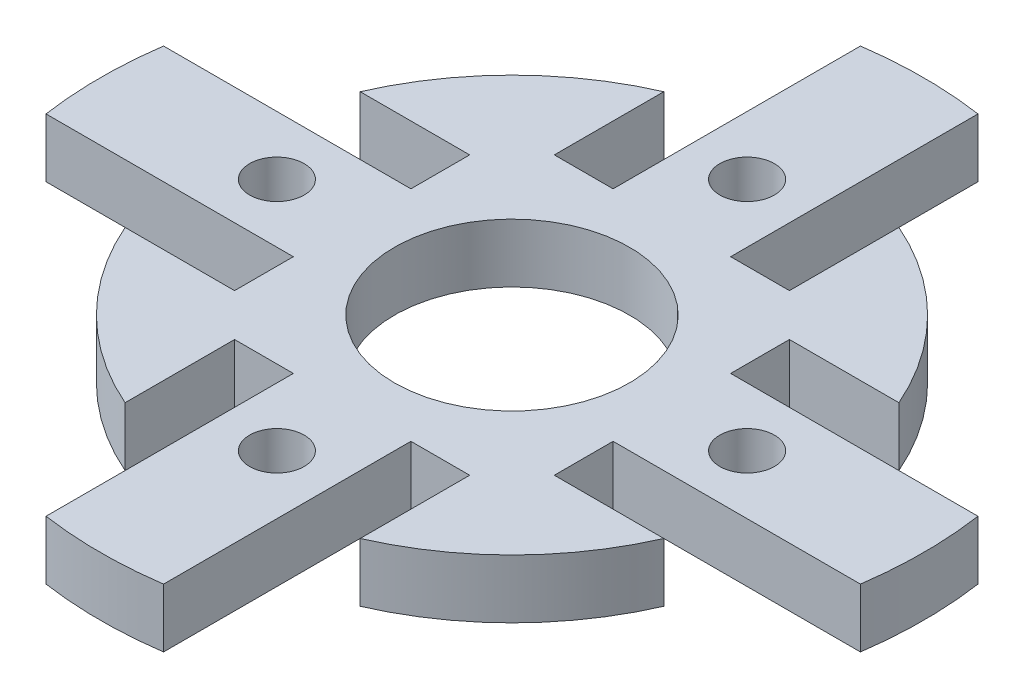
from build123d import *

# Parameters (mm, degrees)
SKETCH1_R                   = 6.35
BOSS_EXTRUDE1_DEPTH         = 3.175
F_4_CLEARANCE_HOLE1_D       = 2.9464
CUT_EXTRUDE1_REACH          = 33.591
SKETCH11_W                  = 3.175
SKETCH11_H                  = 6.918259867
CIRPATTERN2_COUNT           = 4
CIRPATTERN2_COPY_1_REACH    = 33.591
CIRPATTERN2_COPY_1_SKETCH_W = 3.175
CIRPATTERN2_COPY_1_SKETCH_H = 6.918259867
CIRPATTERN2_COPY_2_REACH    = 33.591
CIRPATTERN2_COPY_2_SKETCH_W = 3.175
CIRPATTERN2_COPY_2_SKETCH_H = 6.918259867
CIRPATTERN2_COPY_3_REACH    = 33.591
CIRPATTERN2_COPY_3_SKETCH_W = 3.175
CIRPATTERN2_COPY_3_SKETCH_H = 6.918259867
CIRPATTERN2_COPY_4_REACH    = 33.591
CIRPATTERN2_COPY_4_SKETCH_W = 3.175
CIRPATTERN2_COPY_4_SKETCH_H = 6.918259867
CIRPATTERN2_COPY_5_REACH    = 33.591
CIRPATTERN2_COPY_5_SKETCH_W = 3.175
CIRPATTERN2_COPY_5_SKETCH_H = 6.918259867
CIRPATTERN2_COPY_6_REACH    = 33.591
CIRPATTERN2_COPY_6_SKETCH_W = 3.175
CIRPATTERN2_COPY_6_SKETCH_H = 6.918259867


with BuildPart() as part:
    # Sketch1 → Boss-Extrude1 (new body)
    with BuildSketch(Plane(origin=(0, 0, 0), x_dir=(1, 0, 0), z_dir=(0, 1, 0))):
        with BuildLine():
            Line((-3.175, 21.997045256), (-3.175, 15.554259867))
            ThreePointArc((-3.175, 15.554259867), (-11.225320151, 11.225320151), (-15.554259867, 3.175))
            Line((-15.554259867, 3.175), (-21.997045256, 3.175))
            ThreePointArc((-21.997045256, 3.175), (-22.225, 0), (-21.997045256, -3.175))
            Line((-21.997045256, -3.175), (-15.554259867, -3.175))
            ThreePointArc((-15.554259867, -3.175), (-11.225320151, -11.225320151), (-3.175, -15.554259867))
            Line((-3.175, -15.554259867), (-3.175, -21.997045256))
            ThreePointArc((-3.175, -21.997045256), (0, -22.225), (3.175, -21.997045256))
            Line((3.175, -21.997045256), (3.175, -15.554259867))
            ThreePointArc((3.175, -15.554259867), (11.225320151, -11.225320151), (15.554259867, -3.175))
            Line((15.554259867, -3.175), (21.997045256, -3.175))
            ThreePointArc((21.997045256, -3.175), (22.225, 0), (21.997045256, 3.175))
            Line((21.997045256, 3.175), (15.554259867, 3.175))
            ThreePointArc((15.554259867, 3.175), (11.225320151, 11.225320151), (3.175, 15.554259867))
            Line((3.175, 15.554259867), (3.175, 21.997045256))
            ThreePointArc((3.175, 21.997045256), (0, 22.225), (-3.175, 21.997045256))
        make_face()
        with Locations(Location((0, 0, 0), (0, 0, 270))):
            Circle(SKETCH1_R, mode=Mode.SUBTRACT)
    extrude(amount=BOSS_EXTRUDE1_DEPTH)

    # #4 Clearance Hole1 (through all)
    with Locations(Plane(origin=(-5.152902703, 3.175, -13.741681739), x_dir=(1, 0, 0), z_dir=(0, 1, 0))):
        with Locations((5.152902703, -1.041681739)):
            f_4_clearance_hole1 = Hole(F_4_CLEARANCE_HOLE1_D / 2)

    # Sketch11 → Cut-Extrude1 (cut, up to next)
    with BuildSketch(Plane(origin=(0, 3.175, 0), x_dir=(1, 0, 0), z_dir=(0, 1, 0)), mode=Mode.PRIVATE) as cut_extrude1_sk1:
        with Locations((-4.7625, 12.095129934)):
            Rectangle(SKETCH11_W, SKETCH11_H)
    cut_extrude1_tool1 = extrude(cut_extrude1_sk1.sketch, amount=-CUT_EXTRUDE1_REACH, mode=Mode.PRIVATE) & part.part
    cut_extrude1 = cut_extrude1_tool1.solids().sort_by_distance((-4.7625, 3.175, -12.09513))[0]
    add(cut_extrude1, mode=Mode.SUBTRACT)

    # Mirror1: Cut-Extrude1 across plane
    add(cut_extrude1.mirror(Plane(origin=(0, 0, 0), x_dir=(0, 0, 1), z_dir=(1, 0, 0))), mode=Mode.SUBTRACT)

    # CirPattern2: #4 Clearance Hole1 ×4 about axis
    cirpattern2_axis = Axis((0, 0, 0), (0, 1, 0))
    for i in range(1, CIRPATTERN2_COUNT):
        add(f_4_clearance_hole1.rotate(cirpattern2_axis, i * 360 / CIRPATTERN2_COUNT), mode=Mode.SUBTRACT)

    # CirPattern2 copy 1 sketch → CirPattern2 copy 1 (cut, up to next)
    with BuildSketch(Plane.ZX.offset(3.175), mode=Mode.PRIVATE) as cirpattern2_copy_1_sk1:
        with Locations((-4.7625, -12.095129934)):
            Rectangle(CIRPATTERN2_COPY_1_SKETCH_W, CIRPATTERN2_COPY_1_SKETCH_H)
    cirpattern2_copy_1_tool1 = extrude(cirpattern2_copy_1_sk1.sketch, amount=-CIRPATTERN2_COPY_1_REACH, mode=Mode.PRIVATE) & part.part
    add(cirpattern2_copy_1_tool1.solids().sort_by_distance((-12.09513, 3.175, -4.7625))[0], mode=Mode.SUBTRACT)

    # CirPattern2 copy 2 sketch → CirPattern2 copy 2 (cut, up to next)
    with BuildSketch(Plane(origin=(0, 3.175, 0), x_dir=(1, 0, 0), z_dir=(0, 1, 0)), mode=Mode.PRIVATE) as cirpattern2_copy_2_sk1:
        with Locations((-4.7625, -12.095129934)):
            Rectangle(CIRPATTERN2_COPY_2_SKETCH_W, CIRPATTERN2_COPY_2_SKETCH_H)
    cirpattern2_copy_2_tool1 = extrude(cirpattern2_copy_2_sk1.sketch, amount=-CIRPATTERN2_COPY_2_REACH, mode=Mode.PRIVATE) & part.part
    add(cirpattern2_copy_2_tool1.solids().sort_by_distance((-4.7625, 3.175, 12.09513))[0], mode=Mode.SUBTRACT)

    # CirPattern2 copy 3 sketch → CirPattern2 copy 3 (cut, up to next)
    with BuildSketch(Plane(origin=(0, 3.175, 0), x_dir=(0, 0, -1), z_dir=(0, 1, 0)), mode=Mode.PRIVATE) as cirpattern2_copy_3_sk1:
        with Locations((-4.7625, -12.095129934)):
            Rectangle(CIRPATTERN2_COPY_3_SKETCH_W, CIRPATTERN2_COPY_3_SKETCH_H)
    cirpattern2_copy_3_tool1 = extrude(cirpattern2_copy_3_sk1.sketch, amount=-CIRPATTERN2_COPY_3_REACH, mode=Mode.PRIVATE) & part.part
    add(cirpattern2_copy_3_tool1.solids().sort_by_distance((12.09513, 3.175, 4.7625))[0], mode=Mode.SUBTRACT)

    # CirPattern2 copy 4 sketch → CirPattern2 copy 4 (cut, up to next)
    with BuildSketch(Plane(origin=(0, 3.175, 0), x_dir=(0, 0, -1), z_dir=(0, 1, 0)), mode=Mode.PRIVATE) as cirpattern2_copy_4_sk1:
        with Locations((-4.7625, 12.095129934)):
            Rectangle(CIRPATTERN2_COPY_4_SKETCH_W, CIRPATTERN2_COPY_4_SKETCH_H)
    cirpattern2_copy_4_tool1 = extrude(cirpattern2_copy_4_sk1.sketch, amount=-CIRPATTERN2_COPY_4_REACH, mode=Mode.PRIVATE) & part.part
    add(cirpattern2_copy_4_tool1.solids().sort_by_distance((-12.09513, 3.175, 4.7625))[0], mode=Mode.SUBTRACT)

    # CirPattern2 copy 5 sketch → CirPattern2 copy 5 (cut, up to next)
    with BuildSketch(Plane(origin=(0, 3.175, 0), x_dir=(-1, 0, 0), z_dir=(0, 1, 0)), mode=Mode.PRIVATE) as cirpattern2_copy_5_sk1:
        with Locations((-4.7625, 12.095129934)):
            Rectangle(CIRPATTERN2_COPY_5_SKETCH_W, CIRPATTERN2_COPY_5_SKETCH_H)
    cirpattern2_copy_5_tool1 = extrude(cirpattern2_copy_5_sk1.sketch, amount=-CIRPATTERN2_COPY_5_REACH, mode=Mode.PRIVATE) & part.part
    add(cirpattern2_copy_5_tool1.solids().sort_by_distance((4.7625, 3.175, 12.09513))[0], mode=Mode.SUBTRACT)

    # CirPattern2 copy 6 sketch → CirPattern2 copy 6 (cut, up to next)
    with BuildSketch(Plane.ZX.offset(3.175), mode=Mode.PRIVATE) as cirpattern2_copy_6_sk1:
        with Locations((-4.7625, 12.095129934)):
            Rectangle(CIRPATTERN2_COPY_6_SKETCH_W, CIRPATTERN2_COPY_6_SKETCH_H)
    cirpattern2_copy_6_tool1 = extrude(cirpattern2_copy_6_sk1.sketch, amount=-CIRPATTERN2_COPY_6_REACH, mode=Mode.PRIVATE) & part.part
    add(cirpattern2_copy_6_tool1.solids().sort_by_distance((12.09513, 3.175, -4.7625))[0], mode=Mode.SUBTRACT)


solid = part.part
